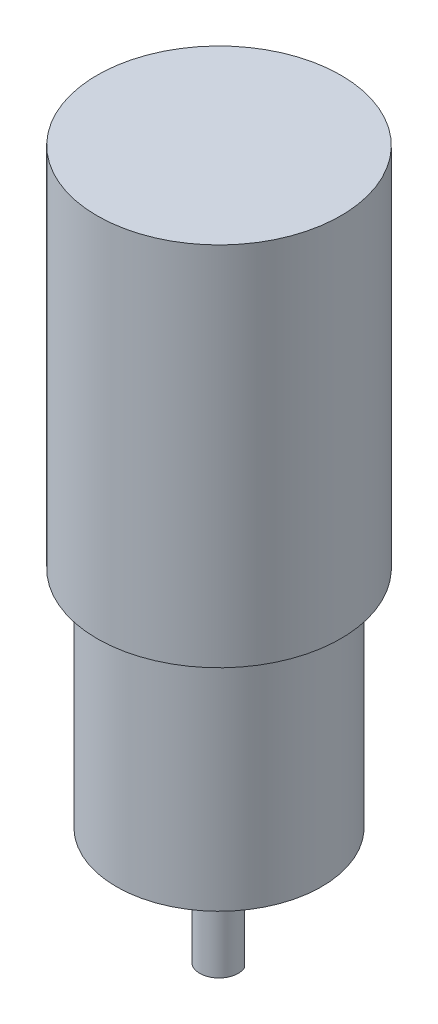
from build123d import *

# Parameters (mm, degrees)
BOSS_EXTRUDE1_DEPTH = 12
BOSS_EXTRUDE2_DEPTH = 3.2
BOSS_EXTRUDE3_DEPTH = 3
SKETCH6_R           = 16
BOSS_EXTRUDE4_DEPTH = 35
SKETCH7_R           = 19
BOSS_EXTRUDE5_DEPTH = 57.1


with BuildPart() as part:
    # Sketch2 → Boss-Extrude1 (new body)
    with BuildSketch(Plane(origin=(0, 0, 0), x_dir=(1, 0, 0), z_dir=(0, 1, 0))):
        with BuildLine():
            Line((2.75, 1.198957881), (-2.75, 1.198957881))
            ThreePointArc((-2.75, 1.198957881), (-0.612372436, -2.936835031), (3, 0))
            ThreePointArc((3, 0), (2.936835031, 0.612372436), (2.75, 1.198957881))
        make_face()
    extrude(amount=BOSS_EXTRUDE1_DEPTH)

    # Sketch3 → Boss-Extrude2 (add)
    with BuildSketch(Plane(origin=(0, 12, 0), x_dir=(1, 0, 0), z_dir=(0, 1, 0))):
        with BuildLine():
            Line((2.75, 1.198957881), (-2.75, 1.198957881))
            ThreePointArc((-2.75, 1.198957881), (-0.612372436, -2.936835031), (3, 0))
            ThreePointArc((3, 0), (2.936835031, 0.612372436), (2.75, 1.198957881))
        make_face()
        with BuildLine():
            ThreePointArc((2.75, 1.198957881), (0, 3), (-2.75, 1.198957881))
            Line((-2.75, 1.198957881), (2.75, 1.198957881))
        make_face()
        with BuildLine():
            ThreePointArc((-2.75, 1.198957881), (0, -3), (2.75, 1.198957881))
            Line((2.75, 1.198957881), (-2.75, 1.198957881))
        make_face()
    extrude(amount=BOSS_EXTRUDE2_DEPTH)

    # Sketch5 → Boss-Extrude3 (add)
    with BuildSketch(Plane(origin=(0, 15.2, 0), x_dir=(1, 0, 0), z_dir=(0, 1, 0))):
        with BuildLine():
            Line((-9, 4.358898944), (-9, -4.358898944))
            ThreePointArc((-9, -4.358898944), (0, -10), (9, -4.358898944))
            Line((9, -4.358898944), (9, 4.358898944))
            ThreePointArc((9, 4.358898944), (0, 10), (-9, 4.358898944))
        make_face()
    extrude(amount=BOSS_EXTRUDE3_DEPTH)

    # Sketch6 → Boss-Extrude4 (add)
    with BuildSketch(Plane(origin=(0, 18.2, 0), x_dir=(1, 0, 0), z_dir=(0, 1, 0))):
        Circle(SKETCH6_R)
    extrude(amount=BOSS_EXTRUDE4_DEPTH)

    # Sketch7 → Boss-Extrude5 (add)
    with BuildSketch(Plane(origin=(0, 53.2, 0), x_dir=(1, 0, 0), z_dir=(0, 1, 0))):
        Circle(SKETCH7_R)
    extrude(amount=BOSS_EXTRUDE5_DEPTH)


solid = part.part
